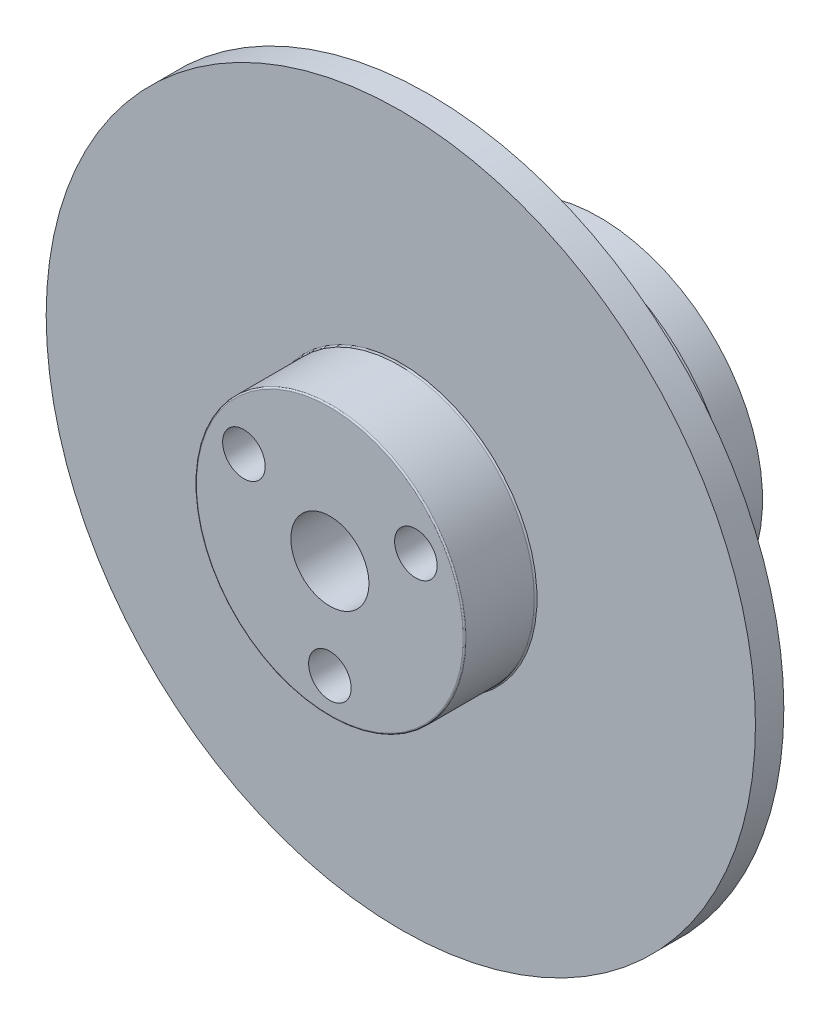
from build123d import *
from build123d.topology import SkipClean

# Parameters (mm, degrees)
SKETCH_2_R                   = 25
SKETCH_2_R_2                 = 10
EXTRUDE_2_DEPTH              = 2
SKETCH_35_R                  = 13.5
EXTRUDE_3_DEPTH              = 2
SKETCH_36_R                  = 12.5
EXTRUDE_4_DEPTH              = 7
HOLE_WIZARD_M3_1_D           = 3.4
HOLE_WIZARD_M3_1_CBORE_D     = 6.5
HOLE_WIZARD_M3_1_CBORE_DEPTH = 3.4
PATTERN_CIRCULAR_1_COUNT     = 3
PATTERN_CIRCULAR_2_COUNT     = 3
EXTRUDE_START                = 3
SKETCH_53_R                  = 11.5
SKETCH_53_R_2                = 1.25
SKETCH_53_R_3                = 3.25
EXTRUDE_5_DEPTH              = 3
EXTRUDE_START_2              = 7
SKETCH_61_R                  = 10
SKETCH_61_R_2                = 1.7
EXTRUDE_6_DEPTH              = 7
SKETCH_62_R                  = 10
SKETCH_62_R_2                = 9.5
CUT_EXTRUDE_1_DEPTH          = 5
FILLET_1_R                   = 0.1
PATTERN_CIRCULAR_3_COUNT     = 3
SKETCH_82_R                  = 3.25
EXTRUDE_7_DEPTH              = 19
HOLE_WIZARD_M5_1_D           = 5.5
HOLE_WIZARD_M5_1_CBORE_D     = 10
HOLE_WIZARD_M5_1_CBORE_DEPTH = 5.4
PATTERN_CIRCULAR_4_COUNT     = 3


with BuildPart() as part:
    # 스케치2 → 보스-돌출2 (new body)
    with BuildSketch(Plane(origin=(0, 6, 0), x_dir=(1, 0, 0), z_dir=(0, 0, -1))):
        with Locations(Location((0, 6, 0), (0, 0, 180))):
            Circle(SKETCH_2_R)
        with Locations(Location((0, 6, 0), (0, 0, 180))):
            Circle(SKETCH_2_R_2, mode=Mode.SUBTRACT)
    extrude(amount=EXTRUDE_2_DEPTH)

    # 스케치35 → 보스-돌출3 (add)
    with BuildSketch(Plane(origin=(0, 0, -2), x_dir=(-1, 0, 0), z_dir=(0, 0, -1))):
        Circle(SKETCH_35_R)
    extrude(amount=EXTRUDE_3_DEPTH)

    # 스케치36 → 보스-돌출4 (add)
    with BuildSketch(Plane(origin=(0, 0, -4), x_dir=(-1, 0, 0), z_dir=(0, 0, -1))):
        Circle(SKETCH_36_R)
    extrude(amount=EXTRUDE_4_DEPTH)

    # Hole Wizard M3 _ _ _ _ _ _1 (through all)
    with Locations(Plane(origin=(0, 0, -11), x_dir=(-1, 0, 0), z_dir=(0, 0, -1))):
        with Locations((0, 4)):
            hole_wizard_m3_1 = CounterBoreHole(HOLE_WIZARD_M3_1_D / 2, HOLE_WIZARD_M3_1_CBORE_D / 2, HOLE_WIZARD_M3_1_CBORE_DEPTH)

    # 원형 패턴1: Hole Wizard M3 _ _ _ _ _ _1 ×3 about axis
    pattern_circular_1_axis = Axis((0, 0, 0), (0, 0, 1))
    for i in range(1, PATTERN_CIRCULAR_1_COUNT):
        add(hole_wizard_m3_1.rotate(pattern_circular_1_axis, i * 360 / PATTERN_CIRCULAR_1_COUNT), mode=Mode.SUBTRACT)

    # 스케치52 → Hole Wizard M3 _ _ _ _1 2 (revolve, cut)
    with BuildSketch(Plane(origin=(0, -7, -11), x_dir=(0, 1, 0), z_dir=(1, 0, 0))):
        Polygon((0, 0), (0, 5.751075774), (1.25, 5), (1.25, 0), align=None)
    hole_wizard_m3_1_2 = revolve(axis=Axis((0, -7, -17.35), (0, 0, 1)), mode=Mode.SUBTRACT)

    # 원형 패턴2: Hole Wizard M3 _ _ _ _1 2 ×3 about axis
    pattern_circular_2_axis = Axis((0, 0, 0), (0, 0, 1))
    for i in range(1, PATTERN_CIRCULAR_2_COUNT):
        add(hole_wizard_m3_1_2.rotate(pattern_circular_2_axis, i * 360 / PATTERN_CIRCULAR_2_COUNT), mode=Mode.SUBTRACT)

    # 스케치53 → 보스-돌출5 (add)
    with SkipClean():  # the faces are left unmerged after this step: merging them gives an invalid solid
        with BuildSketch(Plane(origin=(0, 0, -11), x_dir=(-1, 0, 0), z_dir=(0, 0, -1)).offset(EXTRUDE_START)):
            Circle(SKETCH_53_R)
            with Locations((6.062177826, 3.5)):
                Circle(SKETCH_53_R_2, mode=Mode.SUBTRACT)
            with Locations((0, -7)):
                Circle(SKETCH_53_R_2, mode=Mode.SUBTRACT)
            with Locations((3.464101615, -2)):
                Circle(SKETCH_53_R_3, mode=Mode.SUBTRACT)
            with Locations((0, 4)):
                Circle(SKETCH_53_R_3, mode=Mode.SUBTRACT)
            with Locations((-3.464101615, -2)):
                Circle(SKETCH_53_R_3, mode=Mode.SUBTRACT)
            with Locations((-6.062177826, 3.5)):
                Circle(SKETCH_53_R_2, mode=Mode.SUBTRACT)
        extrude(amount=-EXTRUDE_5_DEPTH)

    # 스케치61 → 보스-돌출6 (add)
    with BuildSketch(Plane.XY.offset(-2).offset(EXTRUDE_START_2)):
        with Locations(Location((0, 0, 0), (0, 0, 180))):
            Circle(SKETCH_61_R)
        with Locations(Location((-3.464101615, -2, 0), (0, 0, 180))):
            Circle(SKETCH_61_R_2, mode=Mode.SUBTRACT)
        with Locations(Location((3.464101615, -2, 0), (0, 0, 180))):
            Circle(SKETCH_61_R_2, mode=Mode.SUBTRACT)
        with Locations(Location((0, 4, 0), (0, 0, 180))):
            Circle(SKETCH_61_R_2, mode=Mode.SUBTRACT)
    extrude(amount=-EXTRUDE_6_DEPTH)

    # 스케치62 → 컷-돌출1 (cut)
    with BuildSketch(Plane.XY.offset(5)):
        Circle(SKETCH_62_R)
        Circle(SKETCH_62_R_2, mode=Mode.SUBTRACT)
    extrude(amount=-CUT_EXTRUDE_1_DEPTH, mode=Mode.SUBTRACT)

    # 필렛1
    fillet_1_edges = [part.edges().sort_by_distance(p)[0] for p in [
        (-9.5, 0, 0),
        (-9.5, 0, 5),
    ]]
    fillet(fillet_1_edges, radius=FILLET_1_R)

    # 스케치67 → Ø3.0mm 맞춤핀 구멍1 (revolve, cut)
    with BuildSketch(Plane(origin=(0, -7, 5), x_dir=(0, -1, 0), z_dir=(1, 0, 0))):
        Polygon((0, 0), (0, 5.901290929), (1.5, 5), (1.5, 0), align=None)
    f_3_0mm_1 = revolve(axis=Axis((0, -7, 11.35), (0, 0, -1)), mode=Mode.SUBTRACT)

    # 원형 패턴3: Ø3.0mm 맞춤핀 구멍1 ×3 about axis
    pattern_circular_3_axis = Axis((0, 0, 0), (0, 0, 1))
    for i in range(1, PATTERN_CIRCULAR_3_COUNT):
        add(f_3_0mm_1.rotate(pattern_circular_3_axis, i * 360 / PATTERN_CIRCULAR_3_COUNT), mode=Mode.SUBTRACT)

    # 스케치82 → 보스-돌출7 (add)
    with SkipClean():  # the faces are left unmerged after this step: merging them gives an invalid solid
        with BuildSketch(Plane(origin=(0, 0, -14), x_dir=(-1, 0, 0), z_dir=(0, 0, -1))):
            with Locations((0, 4)):
                Circle(SKETCH_82_R)
            with Locations((-3.464101615, -2)):
                Circle(SKETCH_82_R)
            with Locations((3.464101615, -2)):
                Circle(SKETCH_82_R)
        extrude(amount=-EXTRUDE_7_DEPTH)

    # M5 육각 소켓 머리 캡 나사용 카운터보어1 (through all)
    with Locations(Plane(origin=(0, 0, -14), x_dir=(-1, 0, 0), z_dir=(0, 0, -1))):
        with Locations((0, 0)):
            CounterBoreHole(HOLE_WIZARD_M5_1_D / 2, HOLE_WIZARD_M5_1_CBORE_D / 2, HOLE_WIZARD_M5_1_CBORE_DEPTH)

    # 스케치89 → Ø3.0mm 맞춤핀 구멍2 (revolve, cut)
    with BuildSketch(Plane(origin=(0, 8.5, -14), x_dir=(0, 1, 0), z_dir=(1, 0, 0))):
        Polygon((0, 0), (0, 5.901290929), (1.5, 5), (1.5, 0), align=None)
    f_3_0mm_2 = revolve(axis=Axis((0, 8.5, -20.35), (0, 0, 1)), mode=Mode.SUBTRACT)

    # 원형 패턴4: Ø3.0mm 맞춤핀 구멍2 ×3 about axis
    pattern_circular_4_axis = Axis((0, 0, 0), (0, 0, 1))
    for i in range(1, PATTERN_CIRCULAR_4_COUNT):
        add(f_3_0mm_2.rotate(pattern_circular_4_axis, i * 360 / PATTERN_CIRCULAR_4_COUNT), mode=Mode.SUBTRACT)


solid = part.part
